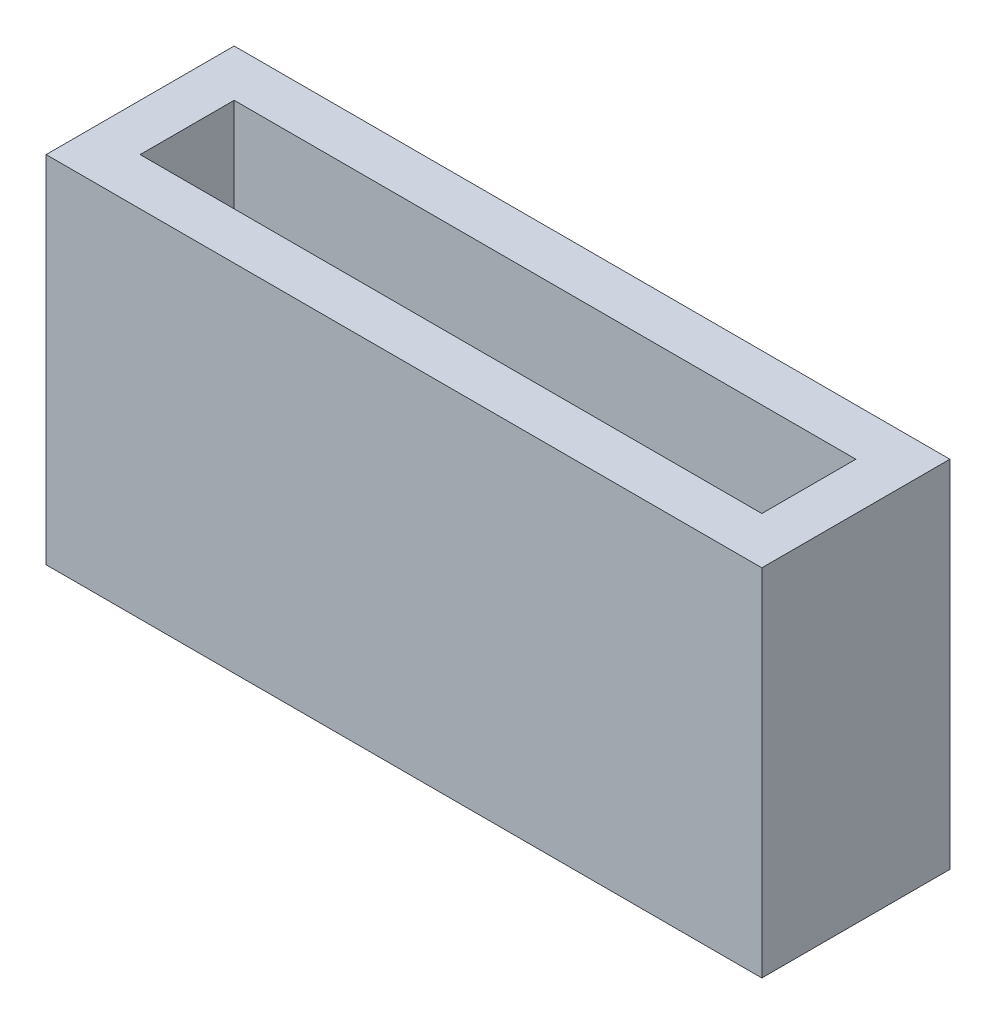
from build123d import *

# Parameters (mm, degrees)
SKETCH1_W           = 34.25
SKETCH1_H           = 9
BOSS_EXTRUDE1_DEPTH = 17
SKETCH2_W           = 29.75
SKETCH2_H           = 4.5
CUT_EXTRUDE1_DEPTH  = 15


with BuildPart() as part:
    # Sketch1 → Boss-Extrude1 (new body)
    with BuildSketch(Plane(origin=(0, 0, 0), x_dir=(1, 0, 0), z_dir=(0, 1, 0))):
        with Locations((-38.045304106, -24.218788439)):
            Rectangle(SKETCH1_W, SKETCH1_H)
    extrude(amount=BOSS_EXTRUDE1_DEPTH)

    # Sketch2 → Cut-Extrude1 (cut)
    with BuildSketch(Plane(origin=(0, 17, 0), x_dir=(1, 0, 0), z_dir=(0, 1, 0))):
        with Locations((-38.045304106, -24.218788439)):
            Rectangle(SKETCH2_W, SKETCH2_H)
    extrude(amount=-CUT_EXTRUDE1_DEPTH, mode=Mode.SUBTRACT)


solid = part.part
